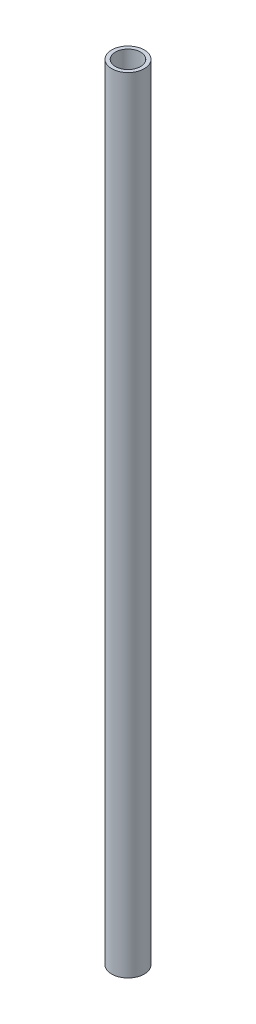
from build123d import *

# Parameters (mm, degrees)
SKETCH2_R           = 5.95
SKETCH2_R_2         = 4.6
BOSS_EXTRUDE1_DEPTH = 286.5


with BuildPart() as part:
    # Sketch2 → Boss-Extrude1 (new body)
    with BuildSketch(Plane(origin=(0, 0, 0), x_dir=(1, 0, 0), z_dir=(0, 1, 0))):
        Circle(SKETCH2_R)
        Circle(SKETCH2_R_2, mode=Mode.SUBTRACT)
    extrude(amount=BOSS_EXTRUDE1_DEPTH)


solid = part.part
